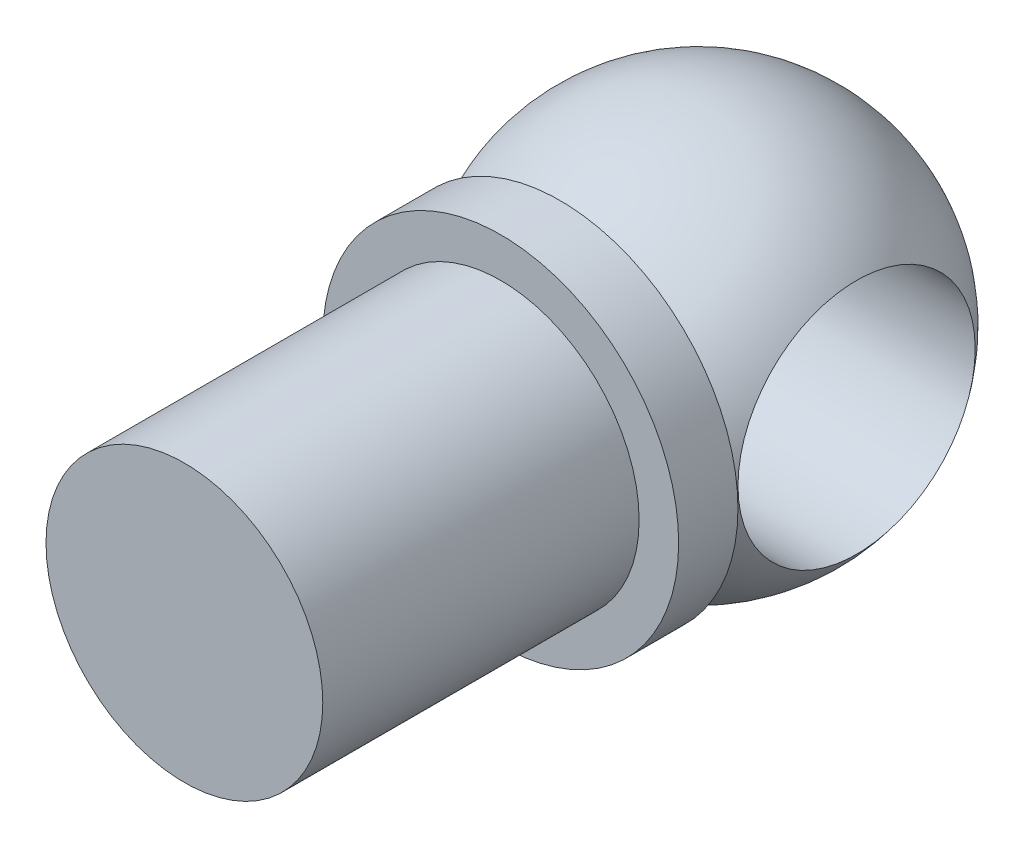
from build123d import *

# Parameters (mm, degrees)
SKETCH_5_R               = 3.5
EXTRUDE_2_DEPTH          = 13
CUT_EXTRUDE_2_DEPTH      = 13
CUT_EXTRUDE_2_DEPTH_BACK = 13
SKETCH_6_R               = 3
SKETCH_7_R               = 4.5
EXTRUDE_3_DEPTH          = 1.5


with BuildPart() as part:
    # 草图1 → 旋转5 (revolve)
    with BuildSketch(Plane(origin=(0, 0, 0), x_dir=(1, 0, 0), z_dir=(0, 1, 0))):
        with BuildLine():
            Line((0, 5), (0, -5))
            ThreePointArc((0, -5), (-5, 0), (0, 5))
        make_face()
    revolve(axis=Axis((0, 0, -5), (0, 0, 1)))

    # 草图5 → 凸台-拉伸2 (add)
    with BuildSketch(Plane.XY):
        Circle(SKETCH_5_R)
    extrude(amount=EXTRUDE_2_DEPTH)

    # 草图6 → 切除-拉伸2 (cut, two sides: drawn at the far end of the back side and taken through both)
    with BuildSketch(Plane(origin=(0, 0, 0), x_dir=(0, 0, -1), z_dir=(1, 0, 0)).offset(-CUT_EXTRUDE_2_DEPTH_BACK)):
        Circle(SKETCH_6_R)
    extrude(amount=CUT_EXTRUDE_2_DEPTH + CUT_EXTRUDE_2_DEPTH_BACK, mode=Mode.SUBTRACT)

    # 草图7 → 凸台-拉伸3 (add)
    with BuildSketch(Plane.XY.offset(5)):
        Circle(SKETCH_7_R)
    extrude(amount=-EXTRUDE_3_DEPTH)


solid = part.part
